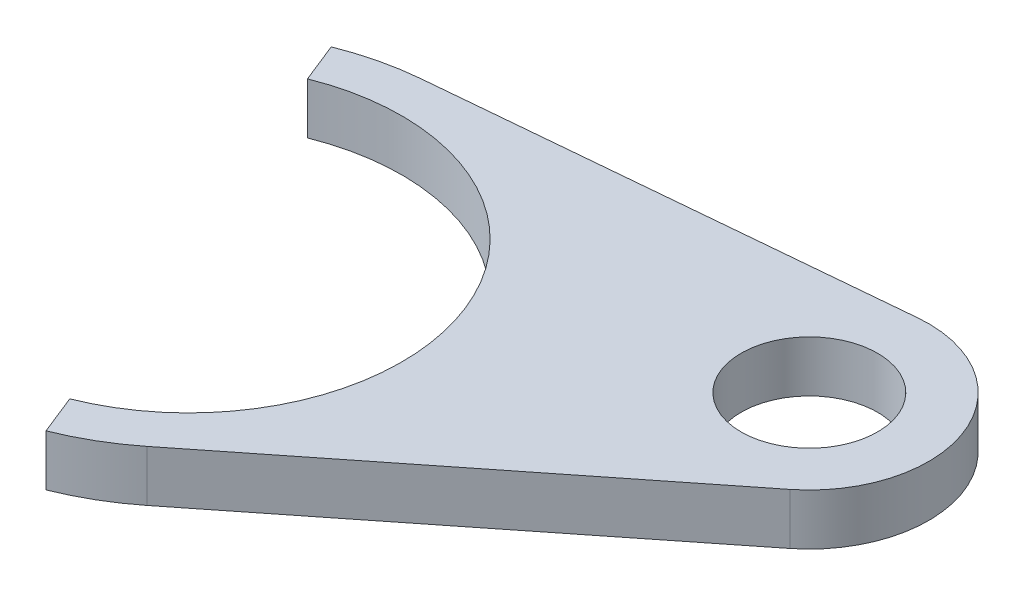
from build123d import *

# Parameters (mm, degrees)
SZKIC1_R                    = 4
DODANIE_WYCI_GNI_CIE1_DEPTH = 3


with BuildPart() as part:
    # Szkic1 → Dodanie-wyciągnięcie1 (new body)
    with BuildSketch(Plane(origin=(0, 0, 0), x_dir=(1, 0, 0), z_dir=(0, 1, 0))):
        with BuildLine():
            Line((-1700.695176003, -413.9172979), (-1679.663082135, -397.254434174))
            ThreePointArc((-1679.663082135, -397.254434174), (-1677.51, -389.169618943), (-1684.642632151, -384.796341157))
            Line((-1684.642632151, -384.796341157), (-1711.365640324, -387.221384291))
            ThreePointArc((-1711.365640324, -387.221384291), (-1713.508120123, -387.573596893), (-1715.577306167, -388.231428571))
            Line((-1715.577306167, -388.231428571), (-1714.649421806, -390.552857143))
            ThreePointArc((-1714.649421806, -390.552857143), (-1698.402857143, -397.520578194), (-1705.370578194, -413.767142857))
            Line((-1705.370578194, -413.767142857), (-1704.442693833, -416.088571429))
            ThreePointArc((-1704.442693833, -416.088571429), (-1702.490155803, -415.138903777), (-1700.695176003, -413.9172979))
        make_face()
        with Locations((-1684.01, -391.767695155)):
            Circle(SZKIC1_R, mode=Mode.SUBTRACT)
    extrude(amount=DODANIE_WYCI_GNI_CIE1_DEPTH)


solid = part.part
